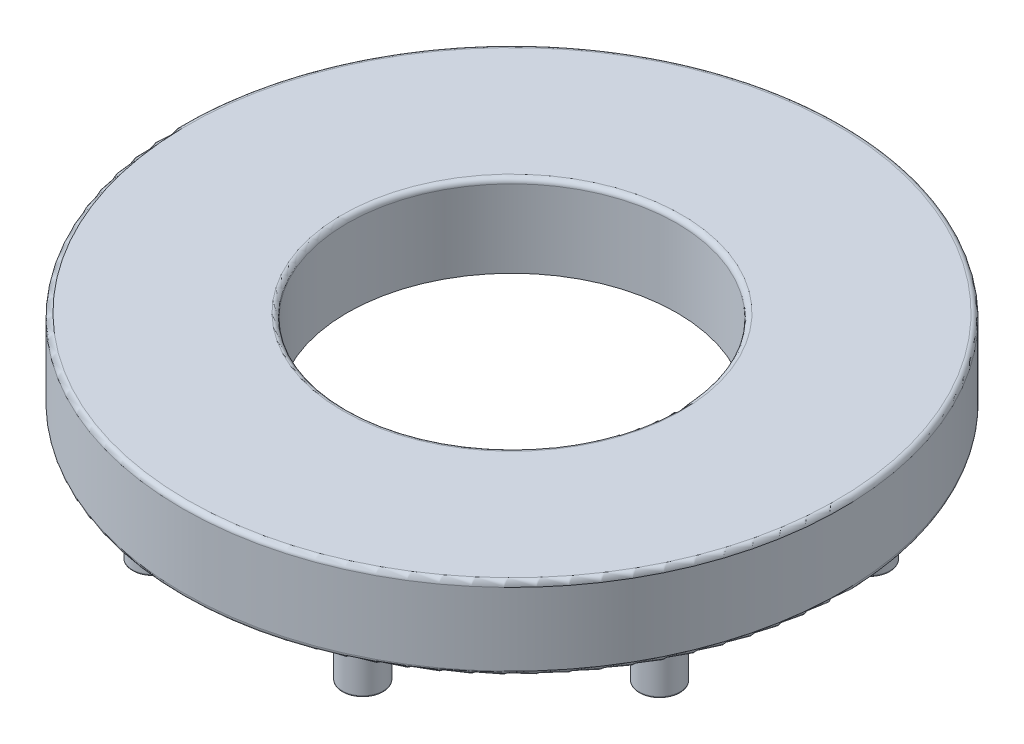
from build123d import *

# Parameters (mm, degrees)
SKETCH1_R           = 2000
SKETCH1_R_2         = 1000
SKETCH1_R_3         = 125
BOSS_EXTRUDE2_DEPTH = 500
SKETCH1_6_R         = 125
BOSS_EXTRUDE3_DEPTH = 500
SKETCH1_7_R         = 125
BOSS_EXTRUDE4_DEPTH = 500
SKETCH3_R           = 125
BOSS_EXTRUDE5_DEPTH = 350
FILLET1_R           = 30
FILLET2_R           = 10


with BuildPart() as part:
    # Sketch1 → Boss-Extrude2 (new body)
    with BuildSketch(Plane(origin=(0, 0, 0), x_dir=(1, 0, 0), z_dir=(0, 1, 0))):
        Circle(SKETCH1_R)
        Circle(SKETCH1_R_2, mode=Mode.SUBTRACT)
        with Locations((-641.811560674, -1537.543513897)):
            Circle(SKETCH1_R_3, mode=Mode.SUBTRACT)
        with Locations((631.942390176, -1537.543513897)):
            Circle(SKETCH1_R_3, mode=Mode.SUBTRACT)
    extrude(amount=BOSS_EXTRUDE2_DEPTH)

    # Sketch1_6 → Boss-Extrude3 (add)
    with BuildSketch(Plane(origin=(0, 0, 0), x_dir=(1, 0, 0), z_dir=(0, 1, 0))):
        with Locations((-641.811560674, -1537.543513897)):
            Circle(SKETCH1_6_R)
    extrude(amount=BOSS_EXTRUDE3_DEPTH)

    # Sketch1_7 → Boss-Extrude4 (add)
    with BuildSketch(Plane(origin=(0, 0, 0), x_dir=(1, 0, 0), z_dir=(0, 1, 0))):
        with Locations((631.942390176, -1537.543513897)):
            Circle(SKETCH1_7_R)
    extrude(amount=BOSS_EXTRUDE4_DEPTH)

    # Sketch3 → Boss-Extrude5 (add)
    with BuildSketch(Plane.XZ):
        with Locations((631.942390176, 1537.543513897)):
            Circle(SKETCH3_R)
        with Locations((-641.811560674, 1537.543513897)):
            Circle(SKETCH3_R)
        with Locations((1537.543513897, 641.811560674)):
            Circle(SKETCH3_R)
        with Locations((1537.543513897, -631.942390176)):
            Circle(SKETCH3_R)
        with Locations((641.811560674, -1537.543513897)):
            Circle(SKETCH3_R)
        with Locations((-631.942390176, -1537.543513897)):
            Circle(SKETCH3_R)
        with Locations((-1537.543513897, -641.811560674)):
            Circle(SKETCH3_R)
        with Locations((-1537.543513897, 631.942390176)):
            Circle(SKETCH3_R)
    extrude(amount=BOSS_EXTRUDE5_DEPTH)

    # Fillet1
    fillet1_edges = [part.edges().sort_by_distance(p)[0] for p in [
        (-2000, 0, 0),
        (-2000, 500, 0),
        (-1000, 500, 0),
    ]]
    fillet(fillet1_edges, radius=FILLET1_R)

    # Fillet2
    fillet2_edges = [part.edges().sort_by_distance(p)[0] for p in [
        (-1662.543513897, -350, 631.942390176),
        (-1662.543513897, -350, -641.811560674),
        (-756.942390176, -350, -1537.543513897),
        (516.811560674, -350, -1537.543513897),
        (1412.543513897, -350, -631.942390176),
        (1412.543513897, -350, 641.811560674),
        (506.942390176, -350, 1537.543513897),
        (-766.811560674, -350, 1537.543513897),
    ]]
    fillet(fillet2_edges, radius=FILLET2_R)


solid = part.part
